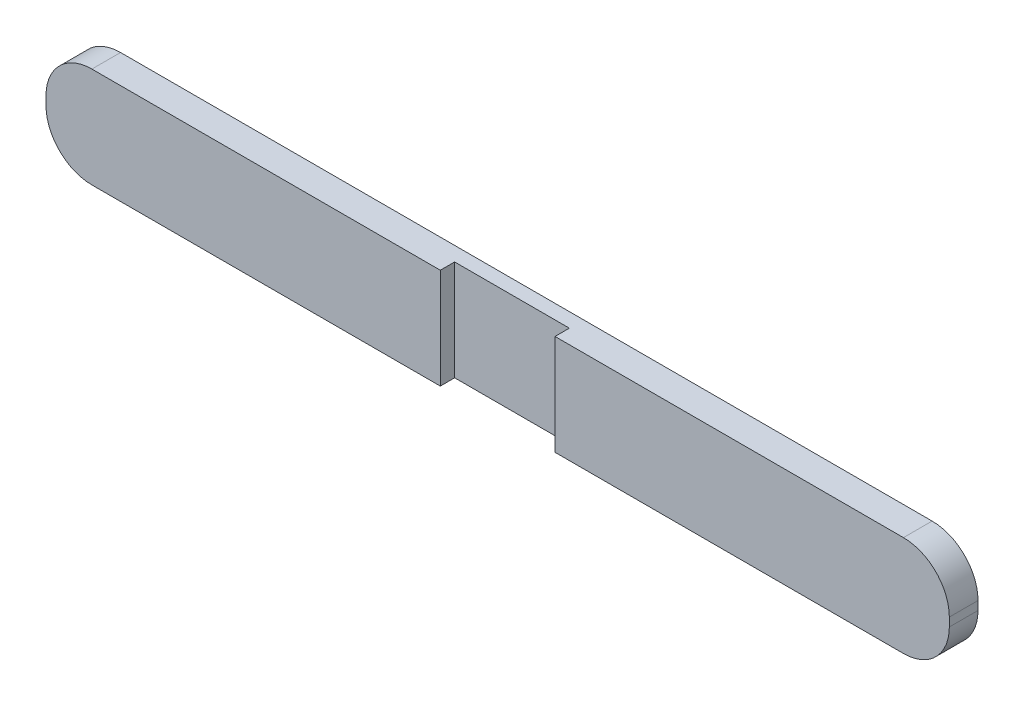
from build123d import *

# Parameters (mm, degrees)
BOSS_EXTRUDE1_DEPTH = 1.5875
SKETCH3_W           = 6.35
SKETCH3_H           = 5.55625
CUT_EXTRUDE1_DEPTH  = 0.79375


with BuildPart() as part:
    # Sketch2 → Boss-Extrude1 (new body)
    with BuildSketch(Plane.XY):
        with BuildLine():
            Line((-16.738445122, 1.796585366), (28.187804878, 1.796585366))
            ThreePointArc((28.187804878, 1.796585366), (29.983856102, 1.05263659), (30.727804878, -0.743414634))
            Line((30.727804878, -0.743414634), (30.727804878, -1.219664634))
            ThreePointArc((30.727804878, -1.219664634), (29.983856102, -3.015715858), (28.187804878, -3.759664634))
            Line((28.187804878, -3.759664634), (-16.738445122, -3.759664634))
            ThreePointArc((-16.738445122, -3.759664634), (-18.534496346, -3.015715858), (-19.278445122, -1.219664634))
            Line((-19.278445122, -1.219664634), (-19.278445122, -0.743414634))
            ThreePointArc((-19.278445122, -0.743414634), (-18.534496346, 1.05263659), (-16.738445122, 1.796585366))
        make_face()
    extrude(amount=BOSS_EXTRUDE1_DEPTH)

    # Sketch3 → Cut-Extrude1 (cut)
    with BuildSketch(Plane.XY.offset(1.5875)):
        with Locations((5.724679878, -0.981539634)):
            Rectangle(SKETCH3_W, SKETCH3_H)
    extrude(amount=-CUT_EXTRUDE1_DEPTH, mode=Mode.SUBTRACT)


solid = part.part
